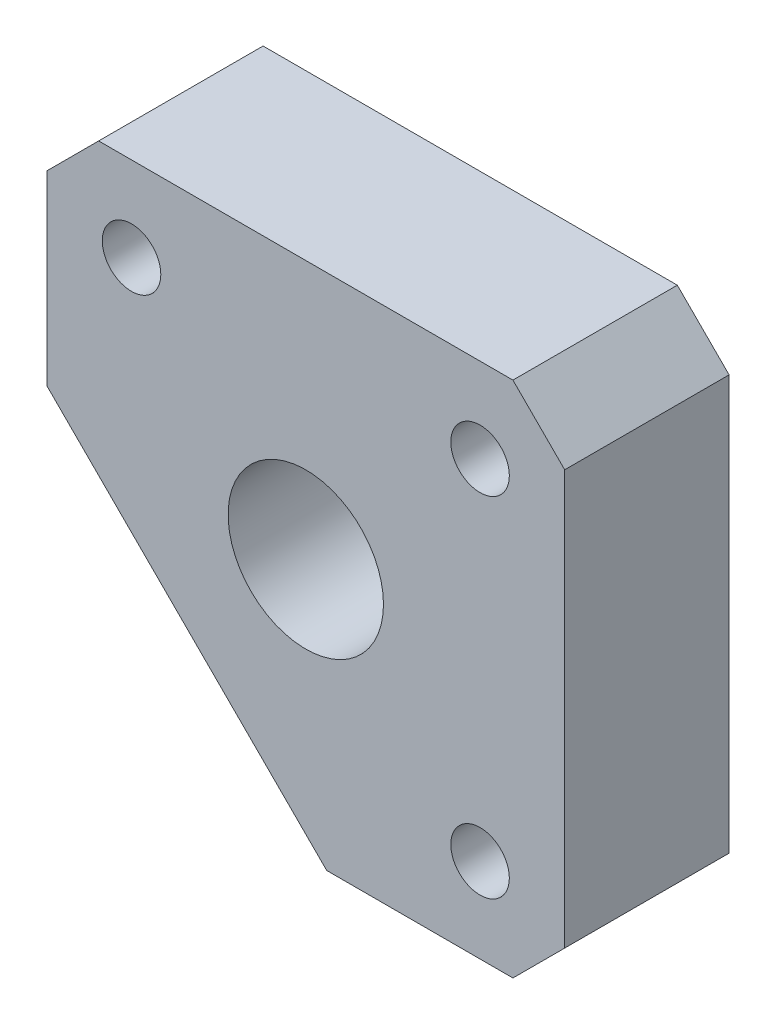
from build123d import *

# Parameters (mm, degrees)
SKETCH1_R             = 3
BOSS_EXTRUDE1_DEPTH   = 6.35
F_4_40_TAPPED_HOLE1_D = 2.2606
CHAMFER1_SIZE         = 2


with BuildPart() as part:
    # Sketch1 → Boss-Extrude1 (new body)
    with BuildSketch(Plane.XY):
        Polygon((-10, 0.807611845), (0.807611845, -10), (10, -10), (10, 10), (-10, 10), align=None)
        Circle(SKETCH1_R, mode=Mode.SUBTRACT)
    extrude(amount=BOSS_EXTRUDE1_DEPTH)

    # 4-40 Tapped Hole1 (through all)
    with Locations(Plane.XY.offset(6.35)):
        with Locations((-6.731, 6.731), (6.731, -6.731), (-6.731, -6.731), (6.731, 6.731)):
            Hole(F_4_40_TAPPED_HOLE1_D / 2)

    # Chamfer1
    chamfer1_edges = [part.edges().sort_by_distance(p)[0] for p in [
        (10, -10, 3.175),
        (10, 10, 3.175),
        (-10, 10, 3.175),
    ]]
    chamfer(chamfer1_edges, length=CHAMFER1_SIZE)


solid = part.part
